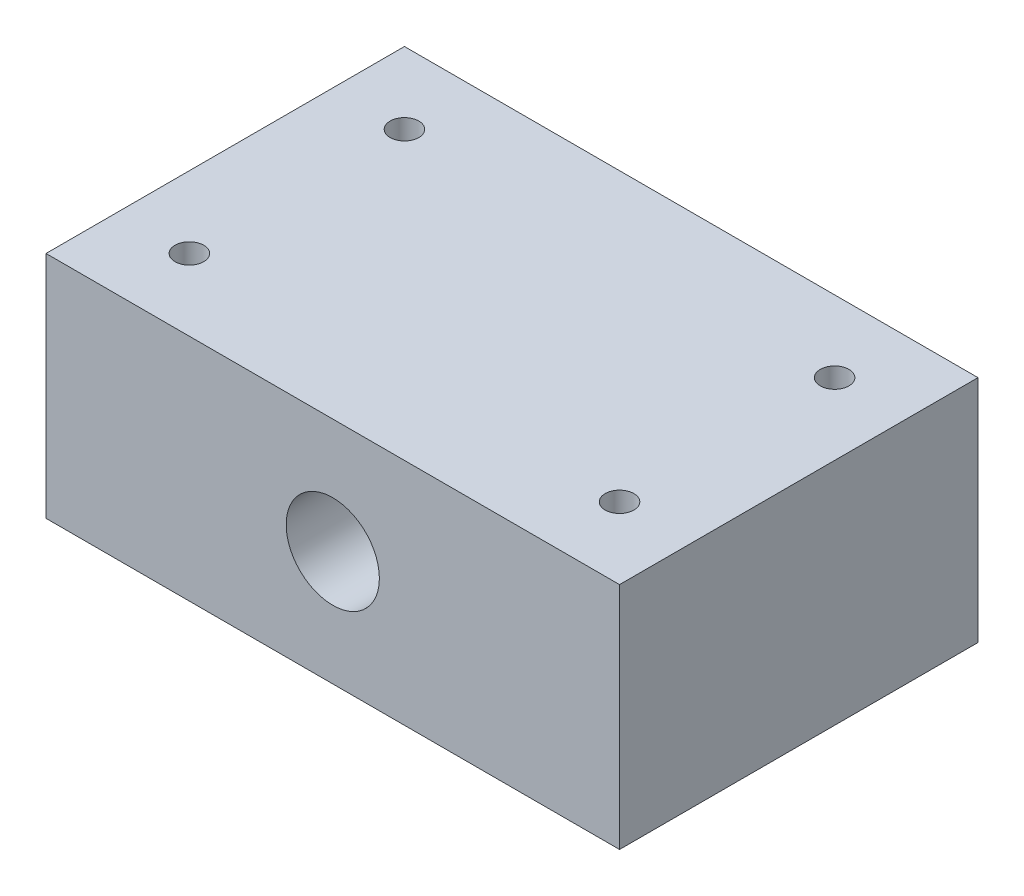
from build123d import *

# Parameters (mm, degrees)
SKETCH1_W           = 80
SKETCH1_H           = 50
SKETCH1_R           = 2
BOSS_EXTRUDE1_DEPTH = 32
SKETCH2_R           = 6.5
CUT_EXTRUDE1_DEPTH  = 51


with BuildPart() as part:
    # Sketch1 → Boss-Extrude1 (new body)
    with BuildSketch(Plane(origin=(0, 0, 0), x_dir=(1, 0, 0), z_dir=(0, 1, 0))):
        with Locations((40, 25)):
            Rectangle(SKETCH1_W, SKETCH1_H)
        with Locations((10, 40)):
            Circle(SKETCH1_R, mode=Mode.SUBTRACT)
        with Locations((70, 40)):
            Circle(SKETCH1_R, mode=Mode.SUBTRACT)
        with Locations((70, 10)):
            Circle(SKETCH1_R, mode=Mode.SUBTRACT)
        with Locations((10, 10)):
            Circle(SKETCH1_R, mode=Mode.SUBTRACT)
    extrude(amount=BOSS_EXTRUDE1_DEPTH)

    # Sketch2 → Cut-Extrude1 (cut, through all)
    with BuildSketch(Plane.XY):
        with Locations((40, 16)):
            Circle(SKETCH2_R)
    extrude(amount=-CUT_EXTRUDE1_DEPTH, mode=Mode.SUBTRACT)


solid = part.part
